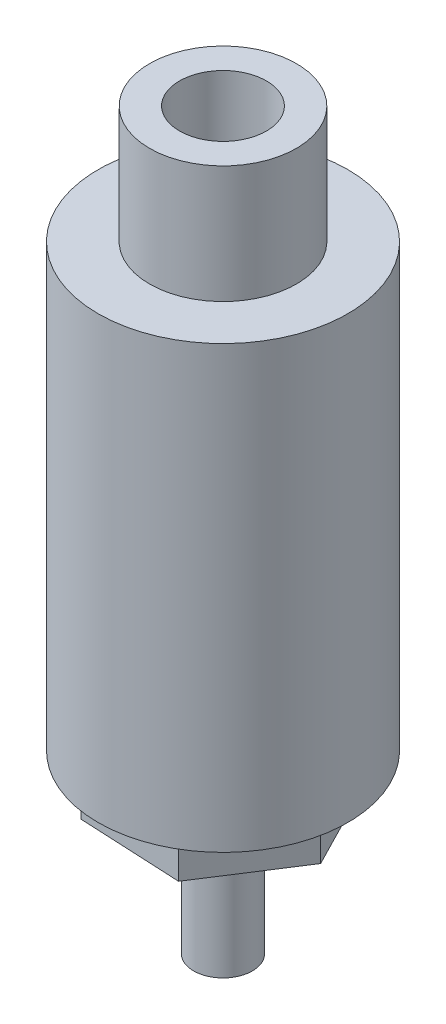
from build123d import *

# Parameters (mm, degrees)
SKETCH1_W           = 8.5
SKETCH1_H           = 30
BOSS_EXTRUDE1_DEPTH = 3
SKETCH3_R           = 5
BOSS_EXTRUDE2_DEPTH = 8
SKETCH4_W           = 2
SKETCH4_H           = 9
HOLE1_D             = 5.917
HOLE1_DEPTH         = 14
HOLE1_TIP           = 1.777646141


with BuildPart() as part:
    # Sketch1 → Revolve1 (revolve)
    with BuildSketch(Plane.XY):
        with Locations((4.25, -15)):
            Rectangle(SKETCH1_W, SKETCH1_H)
    revolve(axis=Axis((0, 0, 0), (0, -1, 0)))

    # Sketch2 → Boss-Extrude1 (add)
    with BuildSketch(Plane.XZ.offset(30)):
        Polygon((-3.79267276, 5.883505191), (3.198928579, 6.226303554), (6.991601339, 0.342798363), (3.79267276, -5.883505191), (-3.198928579, -6.226303554), (-6.991601339, -0.342798363), align=None)
    extrude(amount=BOSS_EXTRUDE1_DEPTH)

    # Sketch3 → Boss-Extrude2 (add)
    with BuildSketch(Plane(origin=(0, 0, 0), x_dir=(-1, 0, 0), z_dir=(0, 1, 0))):
        Circle(SKETCH3_R)
    extrude(amount=BOSS_EXTRUDE2_DEPTH)

    # Sketch4 → Revolve2 (revolve)
    with BuildSketch(Plane.XY):
        with Locations((1, -37.5)):
            Rectangle(SKETCH4_W, SKETCH4_H)
    revolve(axis=Axis((0, -33, 0), (0, -1, 0)))

    # Hole1
    with Locations(Plane(origin=(0, 8, 0), x_dir=(1, 0, 0), z_dir=(0, 1, 0))):
        with Locations((0, 0)):
            Hole(HOLE1_D / 2, depth=HOLE1_DEPTH)
            with Locations((0, 0, -(HOLE1_DEPTH + HOLE1_TIP / 2))):  # 118° drill point
                Cone(0, HOLE1_D / 2, HOLE1_TIP, mode=Mode.SUBTRACT)


solid = part.part
